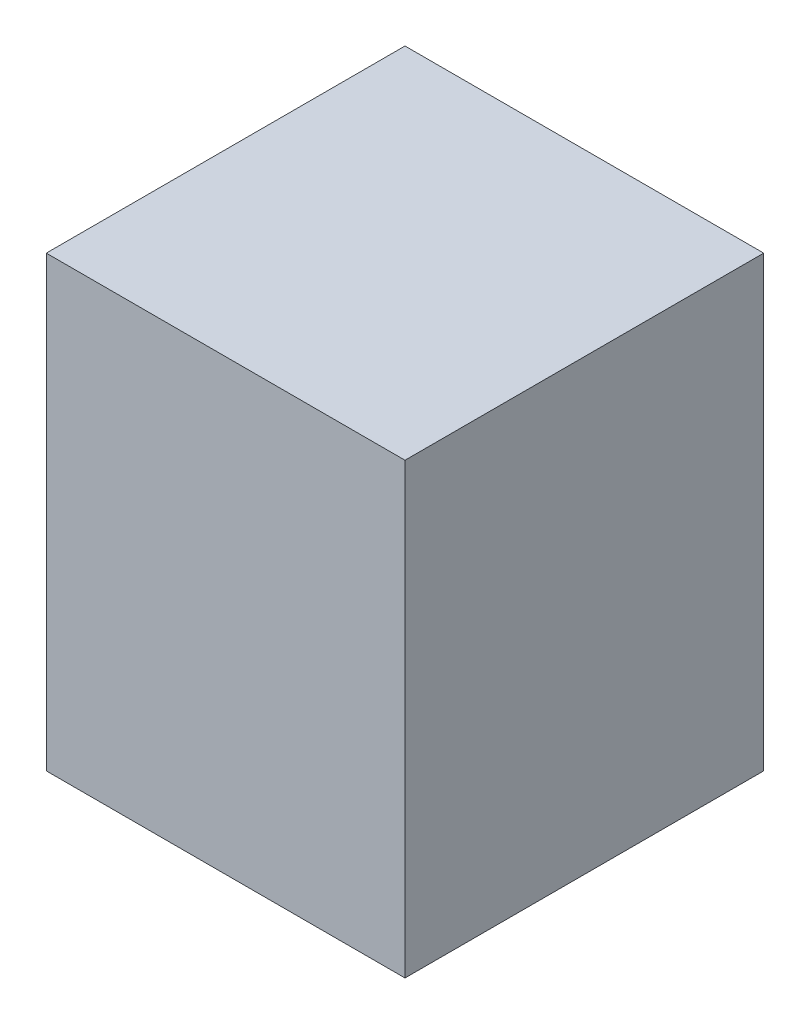
from build123d import *

# Parameters (mm, degrees)
SKETCH1_W           = 12.7
SKETCH1_H           = 12.7
BOSS_EXTRUDE1_DEPTH = 15.875


with BuildPart() as part:
    # Sketch1 → Boss-Extrude1 (new body)
    with BuildSketch(Plane(origin=(0, 0, 0), x_dir=(1, 0, 0), z_dir=(0, 1, 0))):
        with Locations((6.35, 6.35)):
            Rectangle(SKETCH1_W, SKETCH1_H)
    extrude(amount=BOSS_EXTRUDE1_DEPTH)


solid = part.part
